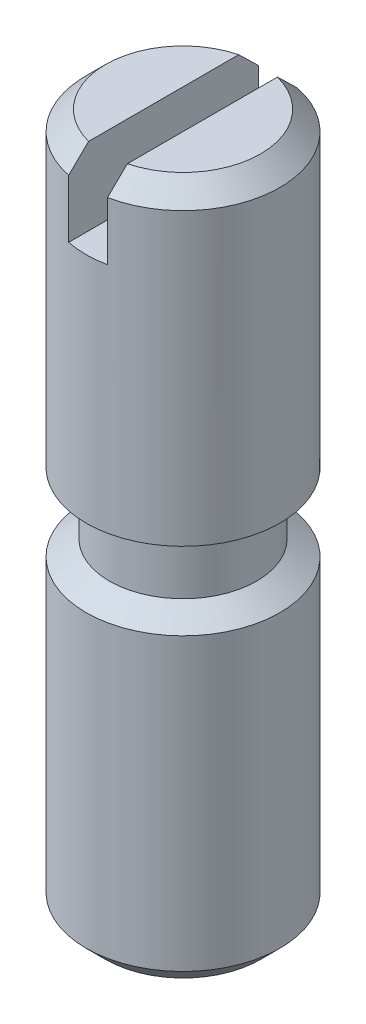
from build123d import *

# Parameters (mm, degrees)
SKIZZE1_R                       = 2.5
AUFSATZ_LINEAR_AUSTRAGEN1_DEPTH = 18
SKIZZE2_W                       = 1
SKIZZE2_H                       = 8.751437557
SCHNITT_LINEAR_AUSTRAGEN1_DEPTH = 2
FASE1_SIZE                      = 0.5


with BuildPart() as part:
    # Skizze1 → Aufsatz-Linear austragen1 (new body)
    with BuildSketch(Plane(origin=(0, 0, 0), x_dir=(1, 0, 0), z_dir=(0, 1, 0))):
        Circle(SKIZZE1_R)
    extrude(amount=AUFSATZ_LINEAR_AUSTRAGEN1_DEPTH)

    # Skizze2 → Schnitt-Linear austragen1 (cut)
    with BuildSketch(Plane(origin=(0, 18, 0), x_dir=(1, 0, 0), z_dir=(0, 1, 0))):
        with Locations((0, -0.571236499)):
            Rectangle(SKIZZE2_W, SKIZZE2_H)
    extrude(amount=-SCHNITT_LINEAR_AUSTRAGEN1_DEPTH, mode=Mode.SUBTRACT)

    # Fase1
    fase1_edges = [part.edges().sort_by_distance(p)[0] for p in [
        (-2.5, 0, 0),
        (1.936491673, 18, 1.58113883),
        (-2.5, 18, 0),
    ]]
    chamfer(fase1_edges, length=FASE1_SIZE)

    # Skizze3 → Schnitt-Rotation1 (revolve, cut)
    with BuildSketch(Plane.XY):
        Polygon((2.5, 10), (1.9, 10), (1.9, 8.404421135), (2.5, 8), align=None)
    revolve(axis=Axis((0, 12.232483269, 0), (0, -1, 0)), mode=Mode.SUBTRACT)


solid = part.part
